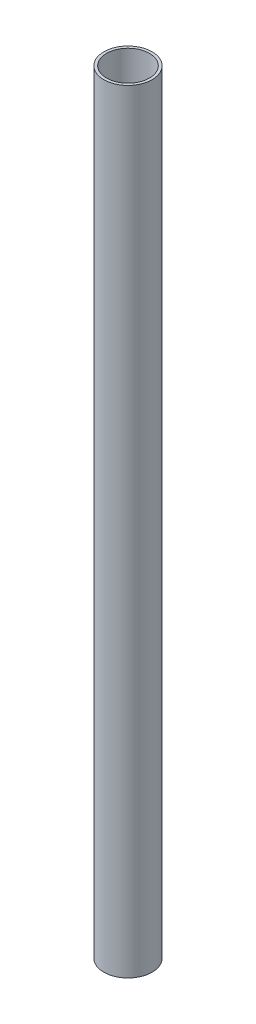
from build123d import *

# Parameters (mm, degrees)
SKETCH1_R           = 6.35
SKETCH1_R_2         = 5.6388
BOSS_EXTRUDE1_DEPTH = 203.2


with BuildPart() as part:
    # Sketch1 → Boss-Extrude1 (new body)
    with BuildSketch(Plane(origin=(0, 0, 0), x_dir=(1, 0, 0), z_dir=(0, 1, 0))):
        Circle(SKETCH1_R)
        Circle(SKETCH1_R_2, mode=Mode.SUBTRACT)
    extrude(amount=BOSS_EXTRUDE1_DEPTH)


solid = part.part
